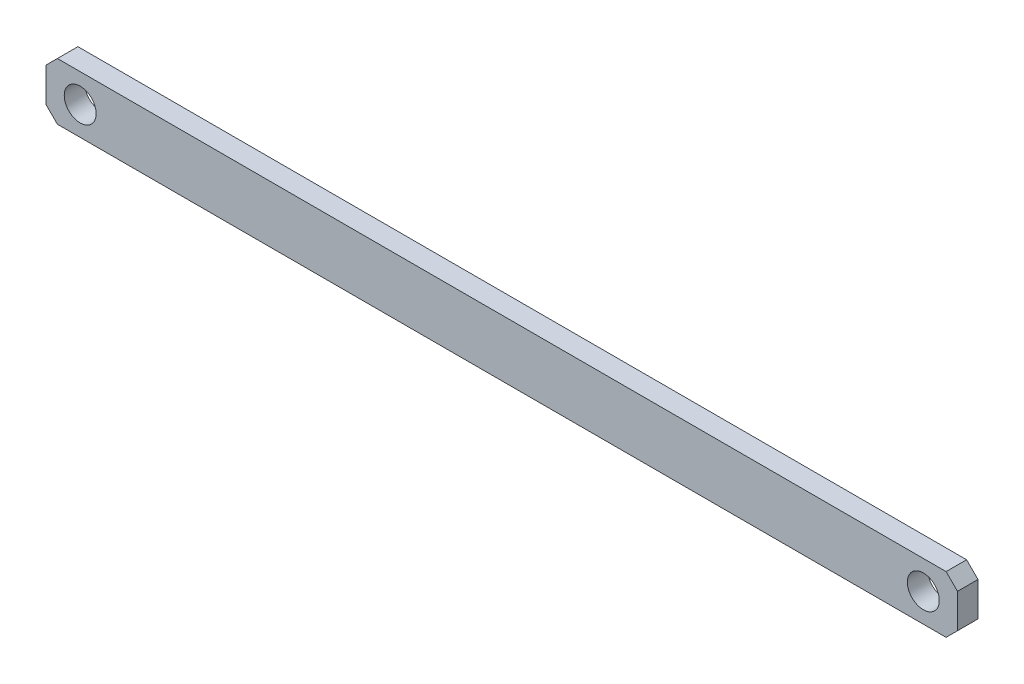
from build123d import *

# Parameters (mm, degrees)
SKETCH_1_R      = 7
EXTRUDE_1_DEPTH = 4.5


with BuildPart() as part:
    # 草圖1 → 填料-伸長1 (new body, symmetric)
    with BuildSketch(Plane.XY):
        Polygon((195, 12.5), (200, 7.5), (200, -7.5), (195, -12.5), (-195, -12.5), (-200, -7.5), (-200, 7.5), (-195, 12.5), align=None)
        with Locations((185, 0)):
            Circle(SKETCH_1_R, mode=Mode.SUBTRACT)
        with Locations((-185, 0)):
            Circle(SKETCH_1_R, mode=Mode.SUBTRACT)
    extrude(amount=EXTRUDE_1_DEPTH, both=True)


solid = part.part
